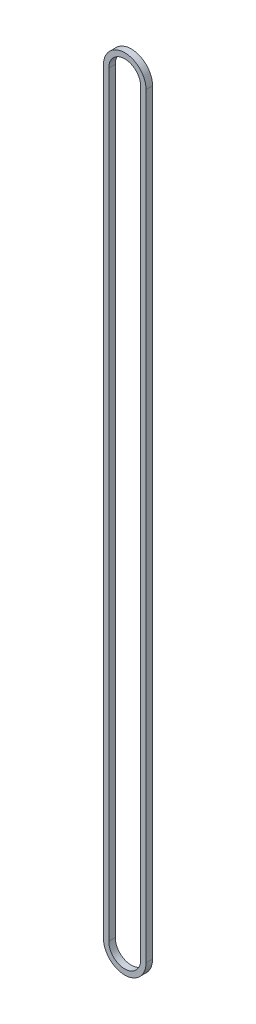
from build123d import *

# Parameters (mm, degrees)
BOSS_EXTRUDE1_DEPTH = 7.7978


with BuildPart() as part:
    # Sketch1 → Boss-Extrude1 (new body)
    with BuildSketch(Plane.XY):
        with BuildLine():
            Line((-25.4, 0), (-25.4, 901.7))
            ThreePointArc((-25.4, 901.7), (0, 927.1), (25.4, 901.7))
            Line((25.4, 901.7), (25.4, 0))
            ThreePointArc((25.4, 0), (0, -25.4), (-25.4, 0))
        make_face()
        with BuildLine():
            Line((-19.05, 0), (-19.05, 901.7))
            ThreePointArc((-19.05, 901.7), (0, 920.75), (19.05, 901.7))
            Line((19.05, 901.7), (19.05, 0))
            ThreePointArc((19.05, 0), (0, -19.05), (-19.05, 0))
        make_face(mode=Mode.SUBTRACT)
    extrude(amount=BOSS_EXTRUDE1_DEPTH)


solid = part.part
